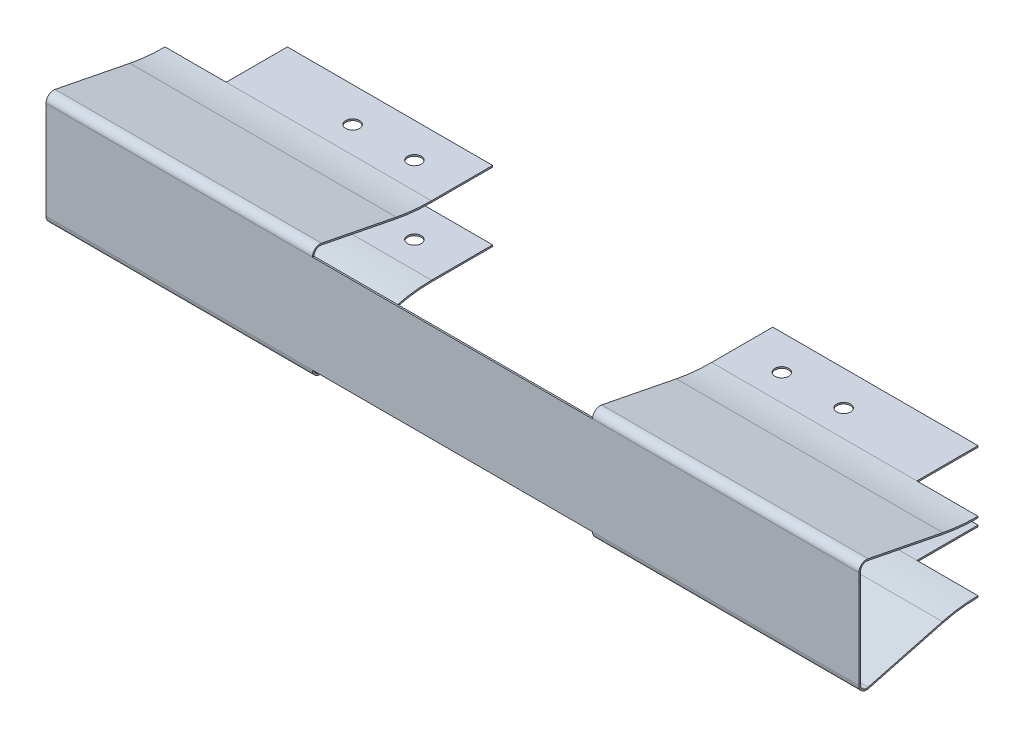
from build123d import *

# Parameters (mm, degrees)
EXTRUDE1_DEPTH          = 66.46
SKETCH2_W               = 45.8
SKETCH2_H               = 1.25
CUT_EXTRUDE1_DEPTH      = 25.47
SKETCH3_W               = 45.8
SKETCH3_H               = 29.22
CUT_EXTRUDE2_DEPTH      = 10.25
CUT_EXTRUDE2_DEPTH_BACK = 10.25
SKETCH4_R               = 1.125
SKETCH4_W               = 10
SKETCH4_H               = 10
CUT_EXTRUDE3_DEPTH      = 10.25
CUT_EXTRUDE3_DEPTH_BACK = 10.25


with BuildPart() as part:
    # Sketch1 → Extrude1 (new body, symmetric)
    with BuildSketch(Plane(origin=(0, 0, 0), x_dir=(0, 0, -1), z_dir=(1, 0, 0))):
        with BuildLine():
            Line((-24.22, 8), (-24.22, -8))
            ThreePointArc((-24.22, -8), (-23.830111825, -8.792315317), (-22.964472878, -8.966801888))
            Line((-22.964472878, -8.966801888), (-10.813561051, -5.755298505))
            ThreePointArc((-10.813561051, -5.755298505), (-7.931209986, -5.189614776), (-5, -5))
            Line((-5, -5), (5, -5))
            Line((5, -5), (5, -5.25))
            Line((5, -5.25), (-5, -5.25))
            ThreePointArc((-5, -5.25), (-7.899000655, -5.437531211), (-10.749679271, -5.996998977))
            Line((-10.749679271, -5.996998977), (-22.900591097, -9.208502359))
            ThreePointArc((-22.900591097, -9.208502359), (-23.982639781, -8.990394146), (-24.47, -8))
            Line((-24.47, -8), (-24.47, 8))
            ThreePointArc((-24.47, 8), (-24.013634161, 8.965735377), (-22.97776829, 9.226304937))
            Line((-22.97776829, 9.226304937), (-10.765114709, 6.8139425))
            ThreePointArc((-10.765114709, 6.8139425), (-7.896315709, 6.391321284), (-5, 6.25))
            Line((-5, 6.25), (5, 6.25))
            Line((5, 6.25), (5, 6))
            Line((5, 6), (-5, 6))
            ThreePointArc((-5, 6), (-7.920654497, 6.142508858), (-10.813561051, 6.568681513))
            Line((-10.813561051, 6.568681513), (-23.026214632, 8.98104395))
            ThreePointArc((-23.026214632, 8.98104395), (-23.854907329, 8.772588302), (-24.22, 8))
        make_face()
    extrude(amount=EXTRUDE1_DEPTH, both=True)

    # Sketch2 → Cut-Extrude1 (cut, through all)
    with BuildSketch(Plane.XY):
        with Locations((0, 8.625)):
            Rectangle(SKETCH2_W, SKETCH2_H)
        with Locations((0, -8.625)):
            Rectangle(SKETCH2_W, SKETCH2_H)
    extrude(amount=CUT_EXTRUDE1_DEPTH, mode=Mode.SUBTRACT)

    # Sketch3 → Cut-Extrude2 (cut, two sides)
    with BuildSketch(Plane(origin=(0, 0, 0), x_dir=(1, 0, 0), z_dir=(0, 1, 0))) as cut_extrude2_sk:
        with Locations((0, -9.61)):
            Rectangle(SKETCH3_W, SKETCH3_H)
    extrude(amount=CUT_EXTRUDE2_DEPTH, mode=Mode.SUBTRACT)
    extrude(cut_extrude2_sk.sketch, amount=-CUT_EXTRUDE2_DEPTH_BACK, mode=Mode.SUBTRACT)

    # Sketch4 → Cut-Extrude3 (cut, two sides)
    with BuildSketch(Plane(origin=(0, 0, 0), x_dir=(1, 0, 0), z_dir=(0, 1, 0))) as cut_extrude3_sk:
        with Locations(Location((-40.14, -0.65, 0), (0, 0, 270))):  # turned: the seam where the file's is
            Circle(SKETCH4_R)
        with Locations(Location((-30.04, -0.65, 0), (0, 0, 270))):  # turned: the seam where the file's is
            Circle(SKETCH4_R)
        with Locations(Location((30.04, -0.65, 0), (0, 0, 270))):  # turned: the seam where the file's is
            Circle(SKETCH4_R)
        with Locations(Location((40.14, -0.65, 0), (0, 0, 270))):  # turned: the seam where the file's is
            Circle(SKETCH4_R)
        with Locations((-61.46, 0)):
            Rectangle(SKETCH4_W, SKETCH4_H)
        with Locations((61.46, 0)):
            Rectangle(SKETCH4_W, SKETCH4_H)
    extrude(amount=CUT_EXTRUDE3_DEPTH, mode=Mode.SUBTRACT)
    extrude(cut_extrude3_sk.sketch, amount=-CUT_EXTRUDE3_DEPTH_BACK, mode=Mode.SUBTRACT)


solid = part.part
